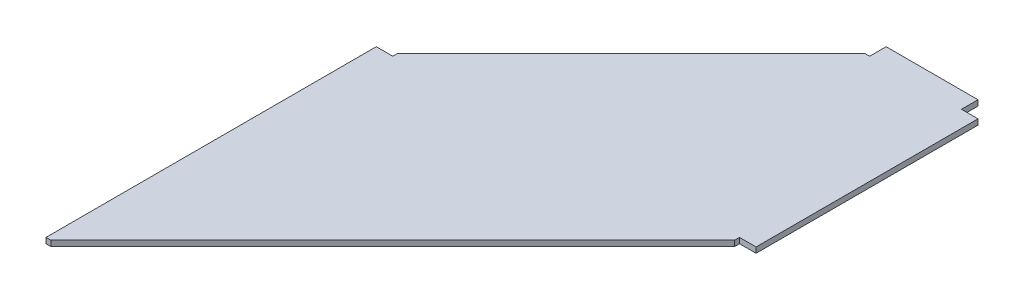
from build123d import *

# Parameters (mm, degrees)
BOSS_EXTRUDE1_DEPTH = 12.7


with BuildPart() as part:
    # Sketch1 → Boss-Extrude1 (new body)
    with BuildSketch(Plane(origin=(0, 0, 0), x_dir=(1, 0, 0), z_dir=(0, 1, 0))):
        Polygon((124.6477263, 198.948104803), (-414.1522737, -339.851895197), (-414.1522737, -351.051895197), (-452.2522737, -351.051895197), (-452.2522737, -1112.951895197), (-441.0522737, -1112.951895197), (347.7477263, -324.251895197), (347.7477263, -313.051895197), (385.8477263, -313.051895197), (385.8477263, 198.948104803), (347.7477263, 198.948104803), (347.7477263, 237.048104803), (135.8477263, 237.048104803), (135.8477263, 198.948104803), align=None)
    extrude(amount=BOSS_EXTRUDE1_DEPTH)


solid = part.part
